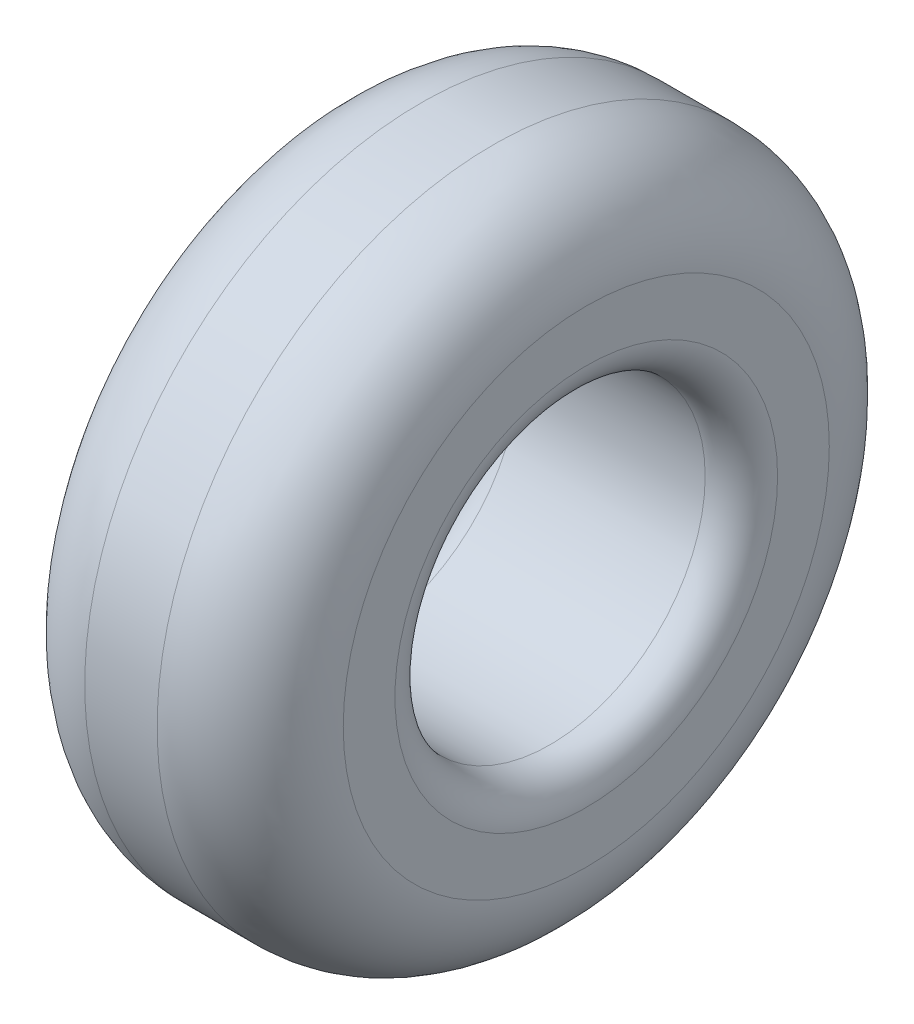
from build123d import *

# Parameters (mm, degrees)
SKETCH1_R           = 165.1
BOSS_EXTRUDE1_DEPTH = 127
SKETCH2_R           = 76.2
CUT_EXTRUDE2_DEPTH  = 128
FILLET1_R           = 17.78
FILLET2_R           = 45.72


with BuildPart() as part:
    # Sketch1 → Boss-Extrude1 (new body)
    with BuildSketch(Plane(origin=(0, 0, 0), x_dir=(0, 0, -1), z_dir=(1, 0, 0))):
        Circle(SKETCH1_R)
    extrude(amount=BOSS_EXTRUDE1_DEPTH)

    # Sketch2 → Cut-Extrude2 (cut, through all)
    with BuildSketch(Plane(origin=(127, 0, 0), x_dir=(0, 0, -1), z_dir=(1, 0, 0))):
        Circle(SKETCH2_R)
    extrude(amount=-CUT_EXTRUDE2_DEPTH, mode=Mode.SUBTRACT)

    # Fillet1
    fillet1_edges = [part.edges().sort_by_distance(p)[0] for p in [
        (0, 0, 76.2),
        (127, 0, 76.2),
    ]]
    fillet(fillet1_edges, radius=FILLET1_R)

    # Fillet2
    fillet2_edges = [part.edges().sort_by_distance(p)[0] for p in [
        (0, 0, 165.1),
        (127, 0, 165.1),
    ]]
    fillet(fillet2_edges, radius=FILLET2_R)


solid = part.part
